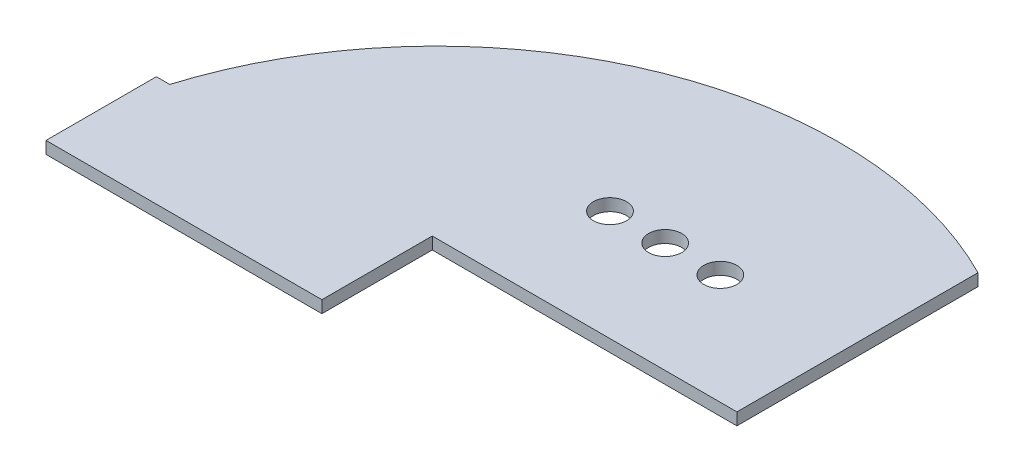
from build123d import *

# Parameters (mm, degrees)
BOSS_EXTRUDE1_DEPTH = 1.1
SKETCH2_R           = 3
CUT_EXTRUDE1_DEPTH  = 3.2


with BuildPart() as part:
    # Sketch1 → Boss-Extrude1 (new body, symmetric)
    with BuildSketch(Plane(origin=(0, 0, 0), x_dir=(1, 0, 0), z_dir=(0, 1, 0))):
        with BuildLine():
            Line((-72.210380265, 1.42), (-22.210380265, 1.42))
            Line((-22.210380265, 1.42), (-22.210380265, 21.42))
            Line((-22.210380265, 21.42), (32.999619735, 21.42))
            Line((32.999619735, 21.42), (32.999619735, 65.115475099))
            ThreePointArc((32.999619735, 65.115475099), (-28.559516246, 67.181500666), (-69.786700739, 21.42))
            Line((-69.786700739, 21.42), (-72.210380265, 21.42))
            Line((-72.210380265, 21.42), (-72.210380265, 1.42))
        make_face()
    extrude(amount=BOSS_EXTRUDE1_DEPTH, both=True)

    # Sketch2 → Cut-Extrude1 (cut, through all)
    with BuildSketch(Plane(origin=(0, 1.1, 0), x_dir=(1, 0, 0), z_dir=(0, 1, 0))):
        with Locations((0, 41.42)):
            Circle(SKETCH2_R)
        with Locations((10, 41.42)):
            Circle(SKETCH2_R)
        with Locations((-10, 41.42)):
            Circle(SKETCH2_R)
    extrude(amount=-CUT_EXTRUDE1_DEPTH, mode=Mode.SUBTRACT)


solid = part.part
